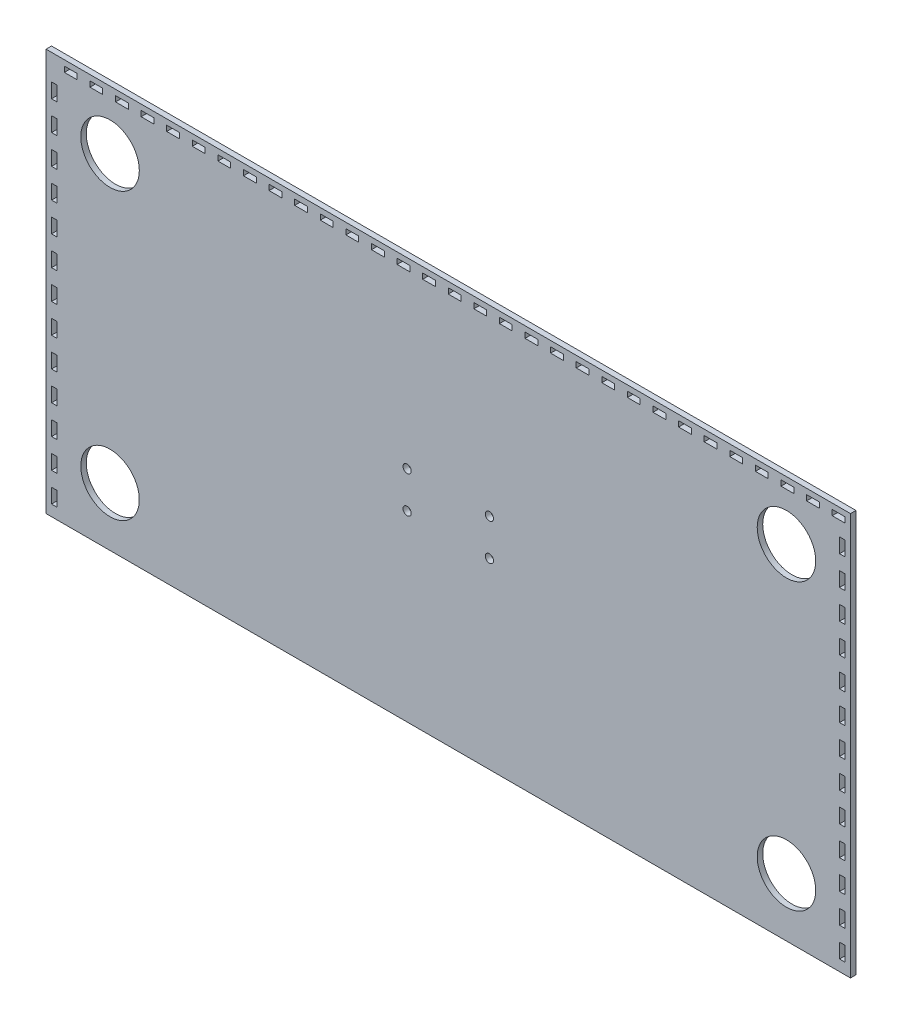
from build123d import *

# Parameters (mm, degrees)
ESQUISSE1_W                      = 440
ESQUISSE1_H                      = 220
BOSS_EXTRU_1_DEPTH               = 3
ESQUISSE2_R                      = 16
ENL_V_MAT_TUBE_DEPTH             = 3
ESQUISSE3_R                      = 2.25
ENL_V_MAT_ECRAN_DEPTH            = 3
ESQUISSE4_W                      = 7
ESQUISSE4_H                      = 3
ENL_V_MAT_C_T_ARRI_REBOITE_DEPTH = 3
ESQUISSE5_W                      = 3
ESQUISSE5_H                      = 8
ENL_V_MAT_C_T_DGBOITE_DEPTH      = 3


with BuildPart() as part:
    # Esquisse1 → Boss.-Extru.1 (new body)
    with BuildSketch(Plane.XY):
        Rectangle(ESQUISSE1_W, ESQUISSE1_H)
    extrude(amount=BOSS_EXTRU_1_DEPTH)

    # Esquisse2 → Enlèv. mat._Tube (cut)
    with BuildSketch(Plane(origin=(0, 0, 0), x_dir=(-1, 0, 0), z_dir=(0, 0, -1))):
        with Locations((-185, 78)):
            Circle(ESQUISSE2_R)
        with Locations((185, 78)):
            Circle(ESQUISSE2_R)
        with Locations((185, -78)):
            Circle(ESQUISSE2_R)
        with Locations((-185, -78)):
            Circle(ESQUISSE2_R)
    extrude(amount=-ENL_V_MAT_TUBE_DEPTH, mode=Mode.SUBTRACT)

    # Esquisse3 → Enlèv. mat._Ecran (cut)
    with BuildSketch(Plane(origin=(0, 0, 0), x_dir=(-1, 0, 0), z_dir=(0, 0, -1))):
        with Locations((-22.5, 10)):
            Circle(ESQUISSE3_R)
        with Locations((22.5, 10)):
            Circle(ESQUISSE3_R)
        with Locations((22.5, -10)):
            Circle(ESQUISSE3_R)
        with Locations((-22.5, -10)):
            Circle(ESQUISSE3_R)
    extrude(amount=-ENL_V_MAT_ECRAN_DEPTH, mode=Mode.SUBTRACT)

    # Esquisse4 → Enlèv. mat._CôtéArrièreBoite (cut)
    with BuildSketch(Plane(origin=(0, 0, 0), x_dir=(-1, 0, 0), z_dir=(0, 0, -1))):
        with Locations((-213.5, 105.5)):
            Rectangle(ESQUISSE4_W, ESQUISSE4_H)
        with Locations((-199.5, 105.5)):
            Rectangle(ESQUISSE4_W, ESQUISSE4_H)
        with Locations((-185.5, 105.5)):
            Rectangle(ESQUISSE4_W, ESQUISSE4_H)
        with Locations((-171.5, 105.5)):
            Rectangle(ESQUISSE4_W, ESQUISSE4_H)
        with Locations((-157.5, 105.5)):
            Rectangle(ESQUISSE4_W, ESQUISSE4_H)
        with Locations((-143.5, 105.5)):
            Rectangle(ESQUISSE4_W, ESQUISSE4_H)
        with Locations((-129.5, 105.5)):
            Rectangle(ESQUISSE4_W, ESQUISSE4_H)
        with Locations((-115.5, 105.5)):
            Rectangle(ESQUISSE4_W, ESQUISSE4_H)
        with Locations((-101.5, 105.5)):
            Rectangle(ESQUISSE4_W, ESQUISSE4_H)
        with Locations((-87.5, 105.5)):
            Rectangle(ESQUISSE4_W, ESQUISSE4_H)
        with Locations((-73.5, 105.5)):
            Rectangle(ESQUISSE4_W, ESQUISSE4_H)
        with Locations((-59.5, 105.5)):
            Rectangle(ESQUISSE4_W, ESQUISSE4_H)
        with Locations((-45.5, 105.5)):
            Rectangle(ESQUISSE4_W, ESQUISSE4_H)
        with Locations((-31.5, 105.5)):
            Rectangle(ESQUISSE4_W, ESQUISSE4_H)
        with Locations((-17.5, 105.5)):
            Rectangle(ESQUISSE4_W, ESQUISSE4_H)
        with Locations((-3.5, 105.5)):
            Rectangle(ESQUISSE4_W, ESQUISSE4_H)
        with Locations((10.5, 105.5)):
            Rectangle(ESQUISSE4_W, ESQUISSE4_H)
        with Locations((24.5, 105.5)):
            Rectangle(ESQUISSE4_W, ESQUISSE4_H)
        with Locations((38.5, 105.5)):
            Rectangle(ESQUISSE4_W, ESQUISSE4_H)
        with Locations((52.5, 105.5)):
            Rectangle(ESQUISSE4_W, ESQUISSE4_H)
        with Locations((66.5, 105.5)):
            Rectangle(ESQUISSE4_W, ESQUISSE4_H)
        with Locations((80.5, 105.5)):
            Rectangle(ESQUISSE4_W, ESQUISSE4_H)
        with Locations((94.5, 105.5)):
            Rectangle(ESQUISSE4_W, ESQUISSE4_H)
        with Locations((108.5, 105.5)):
            Rectangle(ESQUISSE4_W, ESQUISSE4_H)
        with Locations((122.5, 105.5)):
            Rectangle(ESQUISSE4_W, ESQUISSE4_H)
        with Locations((136.5, 105.5)):
            Rectangle(ESQUISSE4_W, ESQUISSE4_H)
        with Locations((150.5, 105.5)):
            Rectangle(ESQUISSE4_W, ESQUISSE4_H)
        with Locations((164.5, 105.5)):
            Rectangle(ESQUISSE4_W, ESQUISSE4_H)
        with Locations((178.5, 105.5)):
            Rectangle(ESQUISSE4_W, ESQUISSE4_H)
        with Locations((192.5, 105.5)):
            Rectangle(ESQUISSE4_W, ESQUISSE4_H)
        with Locations((206.5, 105.5)):
            Rectangle(ESQUISSE4_W, ESQUISSE4_H)
    extrude(amount=-ENL_V_MAT_C_T_ARRI_REBOITE_DEPTH, mode=Mode.SUBTRACT)

    # Esquisse5 → Enlèv. mat.-CôtéDGBoite (cut)
    with BuildSketch(Plane(origin=(0, 0, 0), x_dir=(-1, 0, 0), z_dir=(0, 0, -1))):
        with Locations((-215.5, -100)):
            Rectangle(ESQUISSE5_W, ESQUISSE5_H)
        with Locations((-215.5, -84)):
            Rectangle(ESQUISSE5_W, ESQUISSE5_H)
        with Locations((-215.5, -68)):
            Rectangle(ESQUISSE5_W, ESQUISSE5_H)
        with Locations((-215.5, -52)):
            Rectangle(ESQUISSE5_W, ESQUISSE5_H)
        with Locations((-215.5, -36)):
            Rectangle(ESQUISSE5_W, ESQUISSE5_H)
        with Locations((-215.5, -20)):
            Rectangle(ESQUISSE5_W, ESQUISSE5_H)
        with Locations((-215.5, -4)):
            Rectangle(ESQUISSE5_W, ESQUISSE5_H)
        with Locations((-215.5, 12)):
            Rectangle(ESQUISSE5_W, ESQUISSE5_H)
        with Locations((-215.5, 28)):
            Rectangle(ESQUISSE5_W, ESQUISSE5_H)
        with Locations((-215.5, 44)):
            Rectangle(ESQUISSE5_W, ESQUISSE5_H)
        with Locations((-215.5, 60)):
            Rectangle(ESQUISSE5_W, ESQUISSE5_H)
        with Locations((-215.5, 76)):
            Rectangle(ESQUISSE5_W, ESQUISSE5_H)
        with Locations((-215.5, 92)):
            Rectangle(ESQUISSE5_W, ESQUISSE5_H)
        with Locations((215.5, 92)):
            Rectangle(ESQUISSE5_W, ESQUISSE5_H)
        with Locations((215.5, 76)):
            Rectangle(ESQUISSE5_W, ESQUISSE5_H)
        with Locations((215.5, 60)):
            Rectangle(ESQUISSE5_W, ESQUISSE5_H)
        with Locations((215.5, 44)):
            Rectangle(ESQUISSE5_W, ESQUISSE5_H)
        with Locations((215.5, 28)):
            Rectangle(ESQUISSE5_W, ESQUISSE5_H)
        with Locations((215.5, 12)):
            Rectangle(ESQUISSE5_W, ESQUISSE5_H)
        with Locations((215.5, -4)):
            Rectangle(ESQUISSE5_W, ESQUISSE5_H)
        with Locations((215.5, -20)):
            Rectangle(ESQUISSE5_W, ESQUISSE5_H)
        with Locations((215.5, -36)):
            Rectangle(ESQUISSE5_W, ESQUISSE5_H)
        with Locations((215.5, -52)):
            Rectangle(ESQUISSE5_W, ESQUISSE5_H)
        with Locations((215.5, -68)):
            Rectangle(ESQUISSE5_W, ESQUISSE5_H)
        with Locations((215.5, -84)):
            Rectangle(ESQUISSE5_W, ESQUISSE5_H)
        with Locations((215.5, -100)):
            Rectangle(ESQUISSE5_W, ESQUISSE5_H)
    extrude(amount=-ENL_V_MAT_C_T_DGBOITE_DEPTH, mode=Mode.SUBTRACT)


solid = part.part
